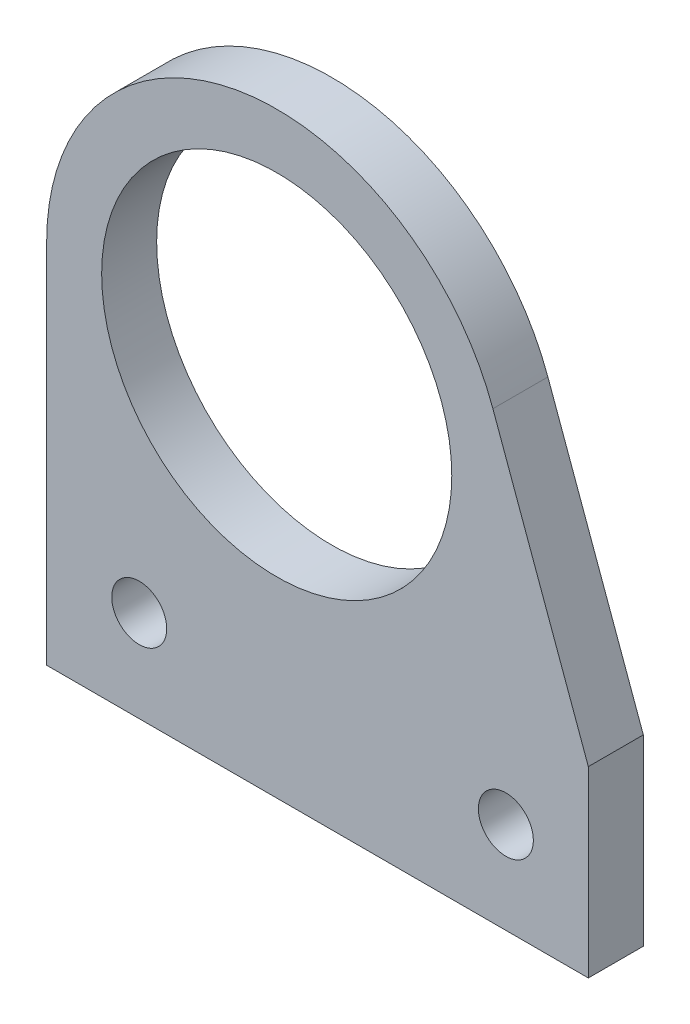
from build123d import *

# Parameters (mm, degrees)
SKETCH_1_R      = 9.55
SKETCH_1_R_2    = 1.5
EXTRUDE_1_DEPTH = 3


with BuildPart() as part:
    # 草图1 → 凸台-拉伸1 (new body)
    with BuildSketch(Plane.XY):
        with BuildLine():
            Line((-12.55, -20), (17, -20))
            Line((17, -20), (17, -10.013370909))
            Line((17, -10.013370909), (11.793142391, 4.292352799))
            ThreePointArc((11.793142391, 4.292352799), (-2.17928463, 12.3593373), (-12.55, 0))
            Line((-12.55, 0), (-12.55, -20))
        make_face()
        Circle(SKETCH_1_R, mode=Mode.SUBTRACT)
        with Locations((-7.5, -15)):
            Circle(SKETCH_1_R_2, mode=Mode.SUBTRACT)
        with Locations((12.5, -15)):
            Circle(SKETCH_1_R_2, mode=Mode.SUBTRACT)
    extrude(amount=EXTRUDE_1_DEPTH)


solid = part.part
